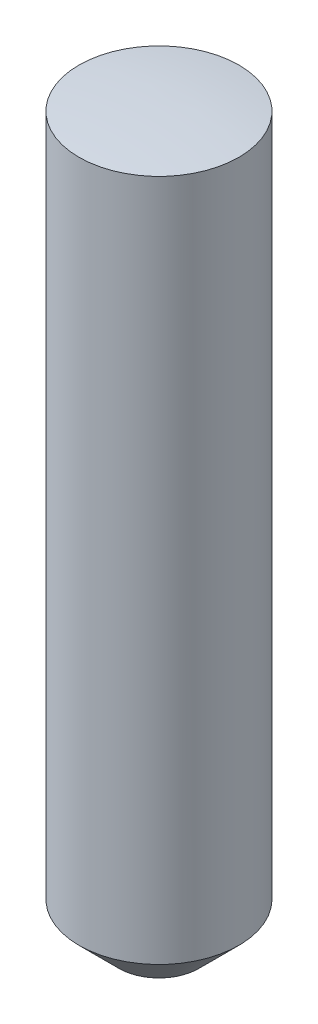
from build123d import *

# Parameters (mm, degrees)
SKETCH1_R                 = 1
BOSS_EXTRUDE_9_10MM_DEPTH = 9.1
F_0_5_X_45_DEG_SIZE       = 0.5


with BuildPart() as part:
    # Sketch1 → Boss-Extrude 9.10mm (new body)
    with BuildSketch(Plane(origin=(0, 0, 0), x_dir=(1, 0, 0), z_dir=(0, 1, 0))):
        Circle(SKETCH1_R)
    extrude(amount=-BOSS_EXTRUDE_9_10MM_DEPTH)

    # 0.5 x 45 deg
    f_0_5_x_45_deg_edges = [part.edges().sort_by_distance(p)[0] for p in [
        (-1, -9.1, 0),
    ]]
    chamfer(f_0_5_x_45_deg_edges, length=F_0_5_X_45_DEG_SIZE)

    # Sketch2 → SR8 (revolve, cut)
    with BuildSketch(Plane.XY):
        with BuildLine():
            Line((0, 2), (-2, 2))
            Line((-2, 2), (-2, -0.254033308))
            ThreePointArc((-2, -0.254033308), (-1.00803434, -0.06376243), (0, 0))
            Line((0, 0), (0, 2))
        make_face()
    revolve(axis=Axis((0, 0, 0), (0, 1, 0)), mode=Mode.SUBTRACT)


solid = part.part
